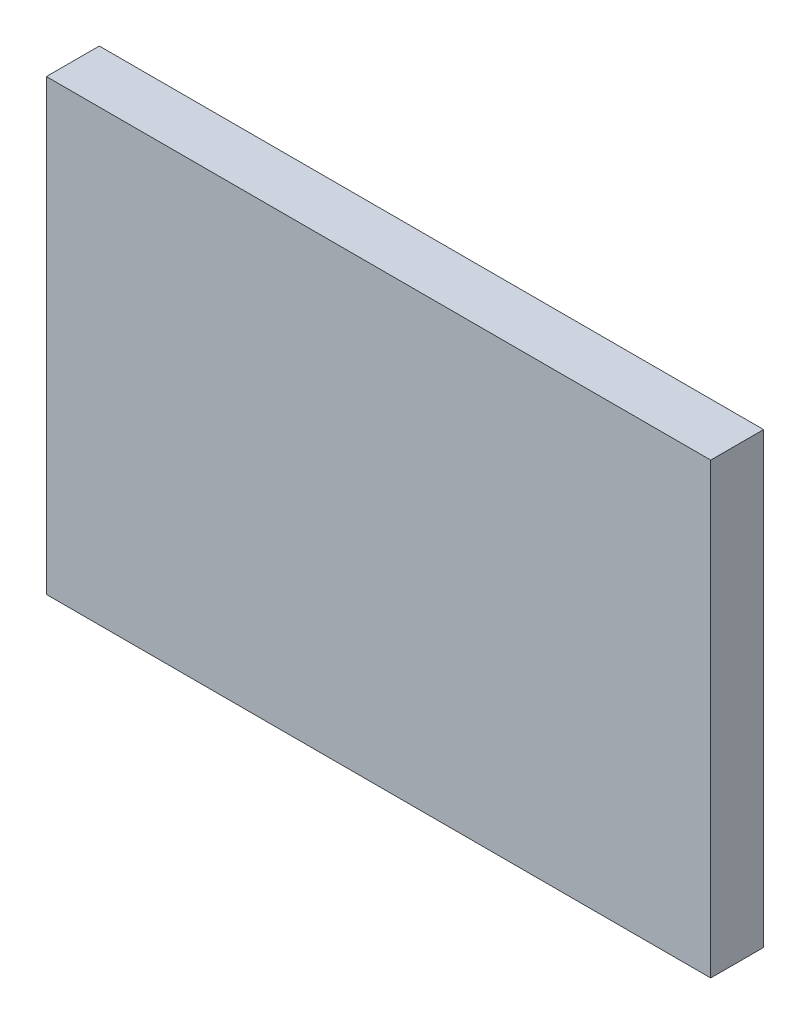
from build123d import *

# Parameters (mm, degrees)
SKETCH1_W           = 39.878
SKETCH1_H           = 26.924
BOSS_EXTRUDE1_DEPTH = 3.175


with BuildPart() as part:
    # Sketch1 → Boss-Extrude1 (new body)
    with BuildSketch(Plane.XY):
        Rectangle(SKETCH1_W, SKETCH1_H)
    extrude(amount=BOSS_EXTRUDE1_DEPTH)


solid = part.part
